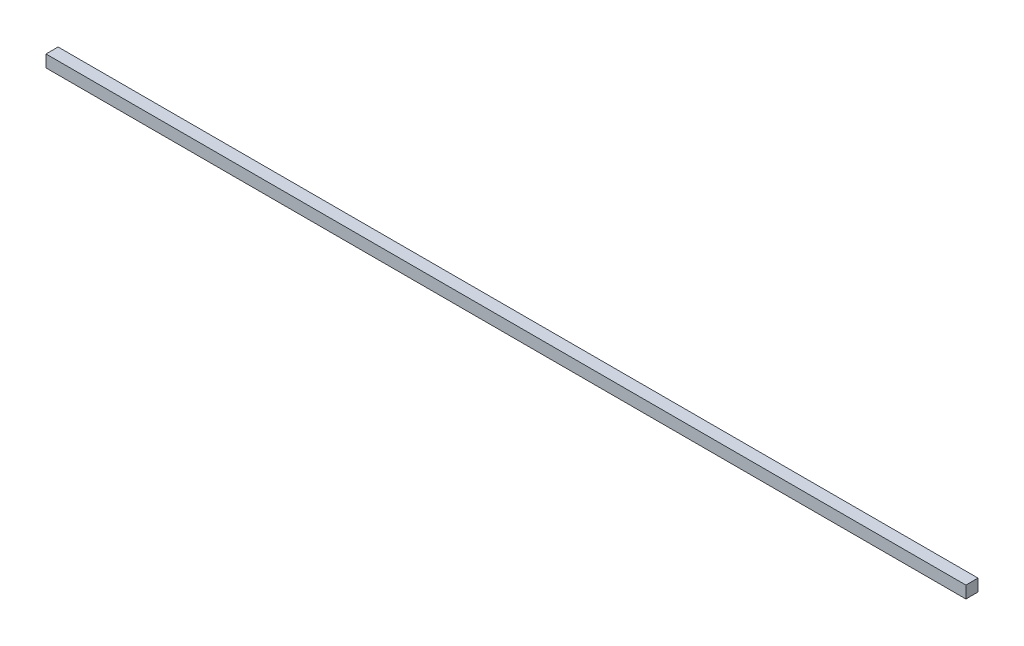
from build123d import *

# Parameters (mm, degrees)
SKETCH1_W           = 760
SKETCH1_H           = 10
BOSS_EXTRUDE1_DEPTH = 10


with BuildPart() as part:
    # Sketch1 → Boss-Extrude1 (new body)
    with BuildSketch(Plane(origin=(0, 0, 0), x_dir=(1, 0, 0), z_dir=(0, 1, 0))):
        Rectangle(SKETCH1_W, SKETCH1_H)
    extrude(amount=BOSS_EXTRUDE1_DEPTH)


solid = part.part
